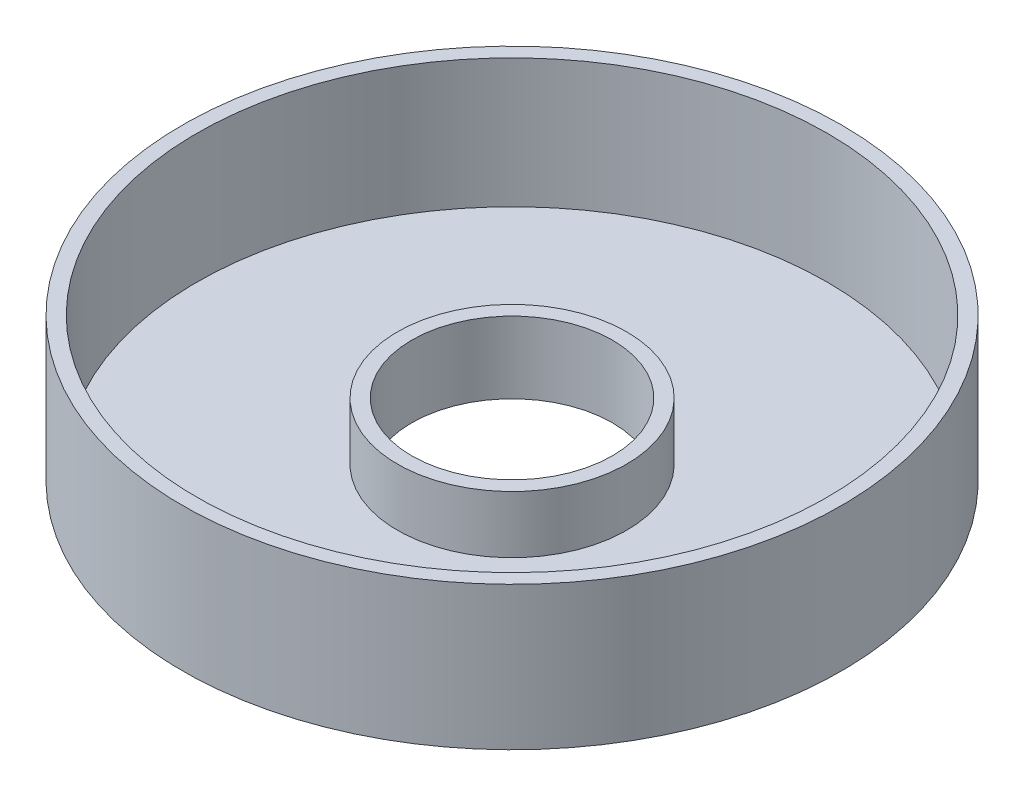
from build123d import *


with BuildPart() as part:
    # Sketch1 → Revolve1 (revolve)
    with BuildSketch(Plane.XY):
        Polygon((-40, 25), (-40, 5), (-110, 5), (-110, 50), (-115, 50), (-115, 0), (-35, 0), (-35, 25), align=None)
    revolve(axis=Axis((0, 0, 0), (0, 1, 0)))


solid = part.part
